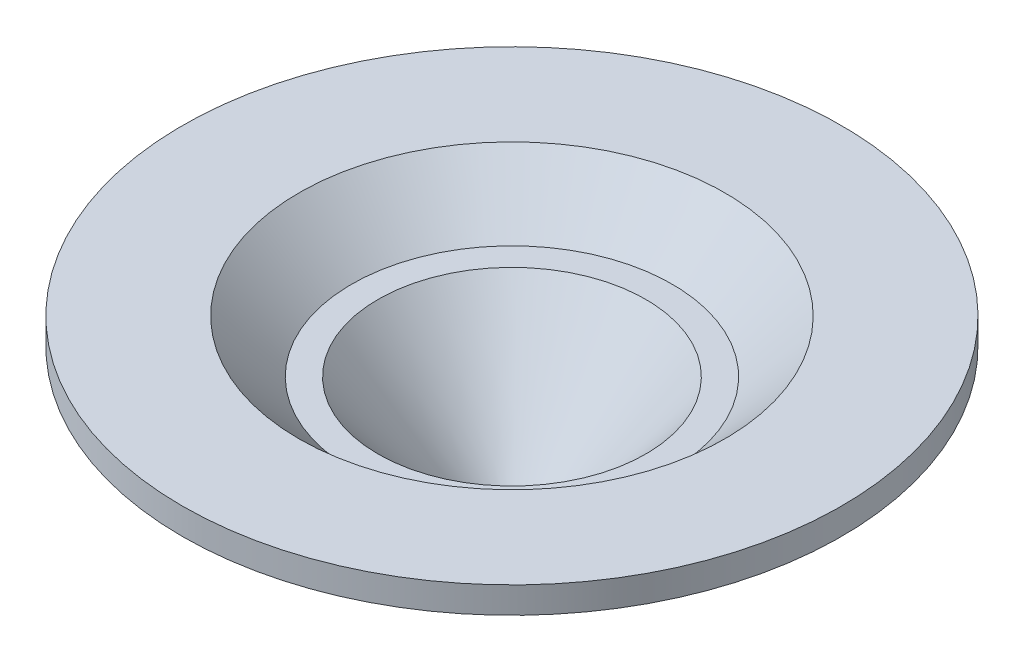
from build123d import *


with BuildPart() as part:
    # Sketch1 → Revolve1 (revolve)
    with BuildSketch(Plane(origin=(0, 0, 0), x_dir=(0, 0, -1), z_dir=(1, 0, 0))):
        Polygon((1, -5), (5.080321285, 0), (6.080321285, 0), (8.080321285, 2), (12.5, 2), (12.5, 1), (10.5, 1), (8.5, -1), (6.5, -1), (2.5, -5), align=None)
    revolve(axis=Axis((0, 0, 0), (0, -1, 0)))


solid = part.part
